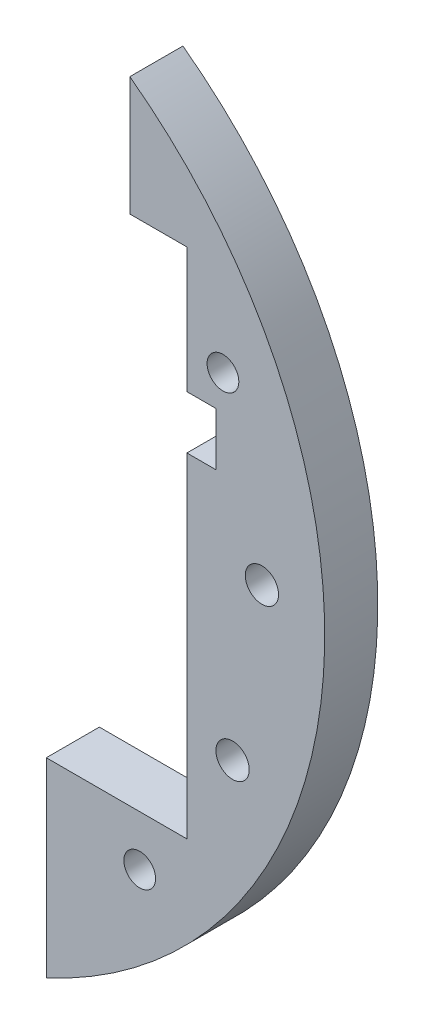
from build123d import *

# Parameters (mm, degrees)
SKETCH1_R           = 57.5
SKETCH1_R_2         = 1.89865
SKETCH1_R_3         = 1.9939
SKETCH1_R_4         = 8
BOSS_EXTRUDE1_DEPTH = 6.35
CUT_EXTRUDE1_DEPTH  = 82.564836173
SKETCH3_W           = 6.35
SKETCH3_H           = 80
CUT_EXTRUDE3_DEPTH  = 82.564836173
CUT_EXTRUDE4_DEPTH  = 82.564836173
CUT_EXTRUDE5_DEPTH  = 78.899883665


with BuildPart() as part:
    # Sketch1 → Boss-Extrude1 (new body)
    with BuildSketch(Plane.XY):
        Circle(SKETCH1_R)
        with Locations((45.315389352, 21.130913087)):
            Circle(SKETCH1_R_2, mode=Mode.SUBTRACT)
        with Locations((46.467376211, -18.460307366)):
            Circle(SKETCH1_R_3, mode=Mode.SUBTRACT)
        Circle(SKETCH1_R_4, mode=Mode.SUBTRACT)
        with Locations((49.978847504, 1.454235937)):
            Circle(SKETCH1_R_3, mode=Mode.SUBTRACT)
        with Locations((0, -40)):
            Circle(SKETCH1_R_3, mode=Mode.SUBTRACT)
        with Locations((0, -50)):
            Circle(SKETCH1_R_2, mode=Mode.SUBTRACT)
        with Locations((-28.284271247, -28.284271247)):
            Circle(SKETCH1_R_3, mode=Mode.SUBTRACT)
        with Locations((-35.355339059, -35.355339059)):
            Circle(SKETCH1_R_2, mode=Mode.SUBTRACT)
        with Locations((-40, 0)):
            Circle(SKETCH1_R_3, mode=Mode.SUBTRACT)
        with Locations((-50, 0)):
            Circle(SKETCH1_R_2, mode=Mode.SUBTRACT)
        with Locations((-28.284271247, 28.284271247)):
            Circle(SKETCH1_R_3, mode=Mode.SUBTRACT)
        with Locations((-35.355339059, 35.355339059)):
            Circle(SKETCH1_R_2, mode=Mode.SUBTRACT)
        with Locations((0, 40)):
            Circle(SKETCH1_R_3, mode=Mode.SUBTRACT)
        with Locations((0, 50)):
            Circle(SKETCH1_R_2, mode=Mode.SUBTRACT)
        with Locations((35.355339059, -35.355339059)):
            Circle(SKETCH1_R_2, mode=Mode.SUBTRACT)
    extrude(amount=BOSS_EXTRUDE1_DEPTH)

    # Sketch2 → Cut-Extrude1 (cut, through all)
    with BuildSketch(Plane.XY):
        Polygon((12.5, -29.35), (41, -29.35), (41, 10.65), (44.5, 10.65), (44.5, 17), (41, 17), (41, 32), (21, 32), (21, 17), (17.5, 17), (17.5, 10.65), (21, 10.65), (21, 5.65), (12.5, 5.65), align=None)
    extrude(amount=CUT_EXTRUDE1_DEPTH, mode=Mode.SUBTRACT)

    # Sketch3 → Cut-Extrude3 (cut, through all)
    with BuildSketch(Plane.XY.offset(6.35)):
        with Locations((31, 32)):
            Rectangle(SKETCH3_W, SKETCH3_H)
    extrude(amount=-CUT_EXTRUDE3_DEPTH, mode=Mode.SUBTRACT)

    # Sketch4 → Cut-Extrude4 (cut, through all)
    with BuildSketch(Plane.XY.offset(6.35)):
        with BuildLine():
            Line((21, -36.5), (21, -16.443021443))
            Line((21, -16.443021443), (24.175, -16.470277755))
            Line((24.175, -16.470277755), (24.175, -57.5))
            Line((24.175, -57.5), (0, -57.5))
            ThreePointArc((0, -57.5), (14.849242405, -51.349242405), (21, -36.5))
        make_face()
        with BuildLine():
            Line((0, 57.5), (24.175, 57.5))
            Line((24.175, 57.5), (24.175, 16.470277755))
            Line((24.175, 16.470277755), (21, 16.443021443))
            Line((21, 16.443021443), (21, 36.5))
            ThreePointArc((21, 36.5), (14.849242405, 51.349242405), (0, 57.5))
        make_face()
    extrude(amount=-CUT_EXTRUDE4_DEPTH, mode=Mode.SUBTRACT)


with BuildPart() as cut_extrude4_piece_1:
    # of the separate pieces the step leaves, piece 1, a body of its own (cut_extrude4_pieces_kept)
    add(part.part.solids().sort_by_distance((24.175, -52.171058787, 0))[0])


with BuildPart() as cut_extrude4_piece_2:
    # of the separate pieces the step leaves, piece 2, a body of its own (cut_extrude4_pieces_kept)
    add(part.part.solids().sort_by_distance((24.175, 52.171058787, 6.35))[0])

    # Sketch5 → Cut-Extrude5 (cut, through all)
    with BuildSketch(Plane.XY.offset(6.35)):
        with BuildLine():
            Line((24.175, 52.171058787), (24.175, 32))
            Line((24.175, 32), (27.825, 32))
            Line((27.825, 32), (27.825, 50.319175023))
            ThreePointArc((27.825, 50.319175023), (26.016482629, 51.277603607), (24.175, 52.171058787))
        make_face()
    extrude(amount=-CUT_EXTRUDE5_DEPTH, mode=Mode.SUBTRACT)


solid = cut_extrude4_piece_1.part
